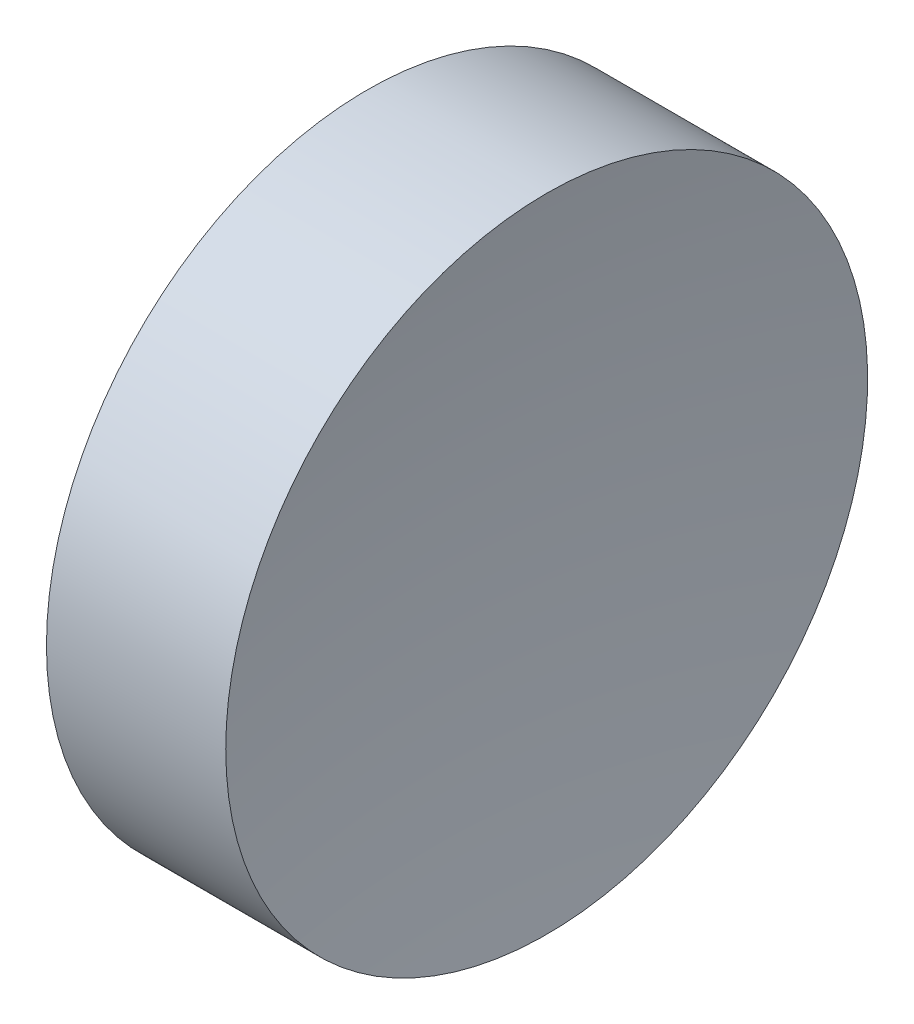
from build123d import *


with BuildPart() as part:
    # 草图1 → 旋转1 (revolve)
    with BuildSketch(Plane.XY):
        with BuildLine():
            Line((57.546327767, 34.689010562), (57.546327767, 40.939010562))
            Line((57.546327767, 40.939010562), (61.037626196, 40.939010562))
            ThreePointArc((61.037626196, 40.939010562), (60.66934153, 37.823650658), (60.546327769, 34.689010562))
            Line((60.546327769, 34.689010562), (57.546327767, 34.689010562))
        make_face()
    revolve(axis=Axis((54.492571501, 34.689010562, 0), (1, 0, 0)))


solid = part.part
